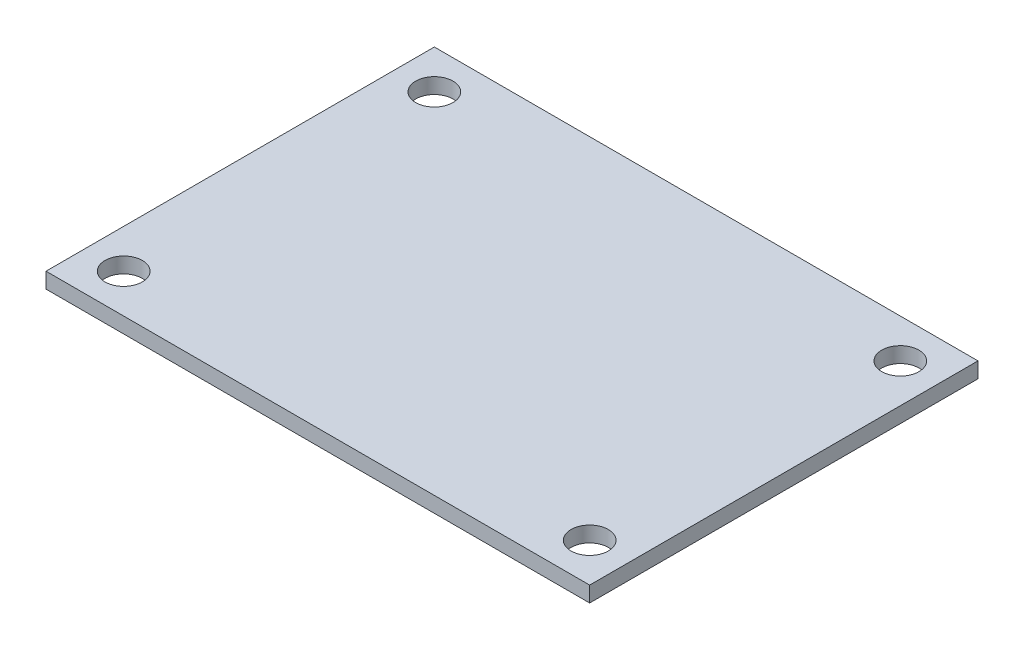
from build123d import *

# Parameters (mm, degrees)
SKICA2_W                 = 35
SKICA2_H                 = 25
P_IDAT_VYSUNUT_M1_DEPTH  = 1
SKICA3_R                 = 1.2
ODEBRAT_VYSUNUT_M1_DEPTH = 1
LINPOLE1_COUNT           = 2
LINPOLE1_PITCH           = 30
LINPOLE1_COUNT_DIR2      = 2
LINPOLE1_PITCH_DIR2      = 20


with BuildPart() as part:
    # Skica2 → Přidat vysunutím1 (new body)
    with BuildSketch(Plane(origin=(0, 0, 0), x_dir=(1, 0, 0), z_dir=(0, 1, 0))):
        Rectangle(SKICA2_W, SKICA2_H)
    extrude(amount=P_IDAT_VYSUNUT_M1_DEPTH)

    # Skica3 → Odebrat vysunutím1 (cut)
    with BuildSketch(Plane(origin=(0, 1, 0), x_dir=(1, 0, 0), z_dir=(0, 1, 0))):
        with Locations((-15, 10)):
            Circle(SKICA3_R)
    odebrat_vysunut_m1 = extrude(amount=-ODEBRAT_VYSUNUT_M1_DEPTH, mode=Mode.SUBTRACT)

    # LinPole1: Odebrat vysunut_m1 2 × 2
    with Locations(*[(i * LINPOLE1_PITCH, 0, j * LINPOLE1_PITCH_DIR2) for i in range(LINPOLE1_COUNT) for j in range(LINPOLE1_COUNT_DIR2) if (i, j) != (0, 0)]):
        add(odebrat_vysunut_m1, mode=Mode.SUBTRACT)


solid = part.part
